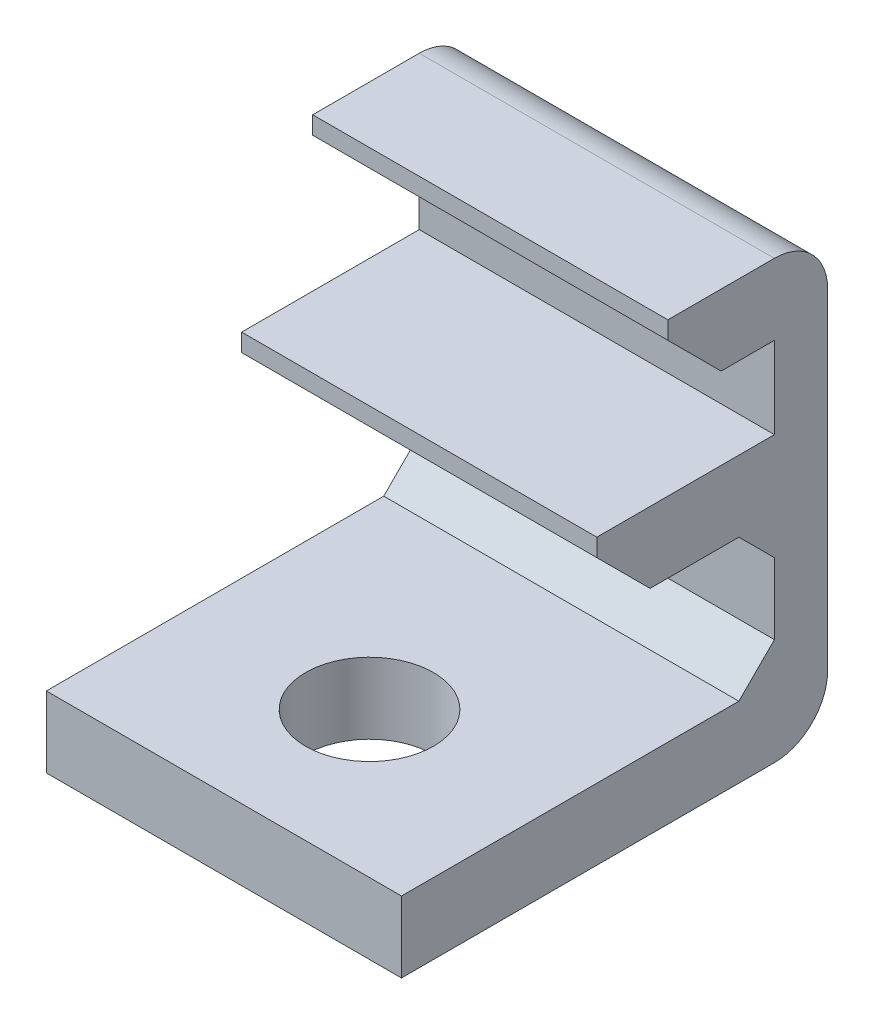
from build123d import *

# Parameters (mm, degrees)
BOSS_EXTRUDE1_DEPTH     = 5
CHAMFER1_SIZE           = 1
SKETCH2_R               = 1.8
CUT_EXTRUDE1_DEPTH      = 3
CUT_EXTRUDE1_DEPTH_BACK = 3
FILLET1_R               = 1.5
CHAMFER2_SIZE           = 1.5


with BuildPart() as part:
    # Sketch1 → Boss-Extrude1 (new body, symmetric)
    with BuildSketch(Plane(origin=(0, 0, 0), x_dir=(0, 0, -1), z_dir=(1, 0, 0))):
        Polygon((-5.25, -4.15), (-5.25, -6.15), (6.75, -6.15), (6.75, 6.15), (2.25, 6.15), (2.25, 4.15), (5.25, 4.15), (5.25, 1.85), (0.25, 1.85), (0.25, -0.15), (5.25, -0.15), (5.25, -4.15), align=None)
    extrude(amount=BOSS_EXTRUDE1_DEPTH, both=True)

    # Chamfer1
    chamfer1_edges = [part.edges().sort_by_distance(p)[0] for p in [
        (0, -4.15, -5.25),
        (0, -0.15, -5.25),
    ]]
    chamfer(chamfer1_edges, length=CHAMFER1_SIZE)

    # Sketch2 → Cut-Extrude1 (cut, two sides)
    with BuildSketch(Plane(origin=(0, -4.15, 0), x_dir=(1, 0, 0), z_dir=(0, 1, 0))) as cut_extrude1_sk:
        with Locations((0, -1.15)):
            Circle(SKETCH2_R)
    extrude(amount=CUT_EXTRUDE1_DEPTH, mode=Mode.SUBTRACT)
    extrude(cut_extrude1_sk.sketch, amount=-CUT_EXTRUDE1_DEPTH_BACK, mode=Mode.SUBTRACT)

    # Fillet1
    fillet1_edges = [part.edges().sort_by_distance(p)[0] for p in [
        (0, 6.15, -6.75),
        (0, -6.15, -6.75),
    ]]
    fillet(fillet1_edges, radius=FILLET1_R)

    # Chamfer2
    chamfer2_edges = [part.edges().sort_by_distance(p)[0] for p in [
        (0, 4.15, -2.25),
        (0, -0.15, -0.25),
    ]]
    chamfer(chamfer2_edges, length=CHAMFER2_SIZE)


solid = part.part
